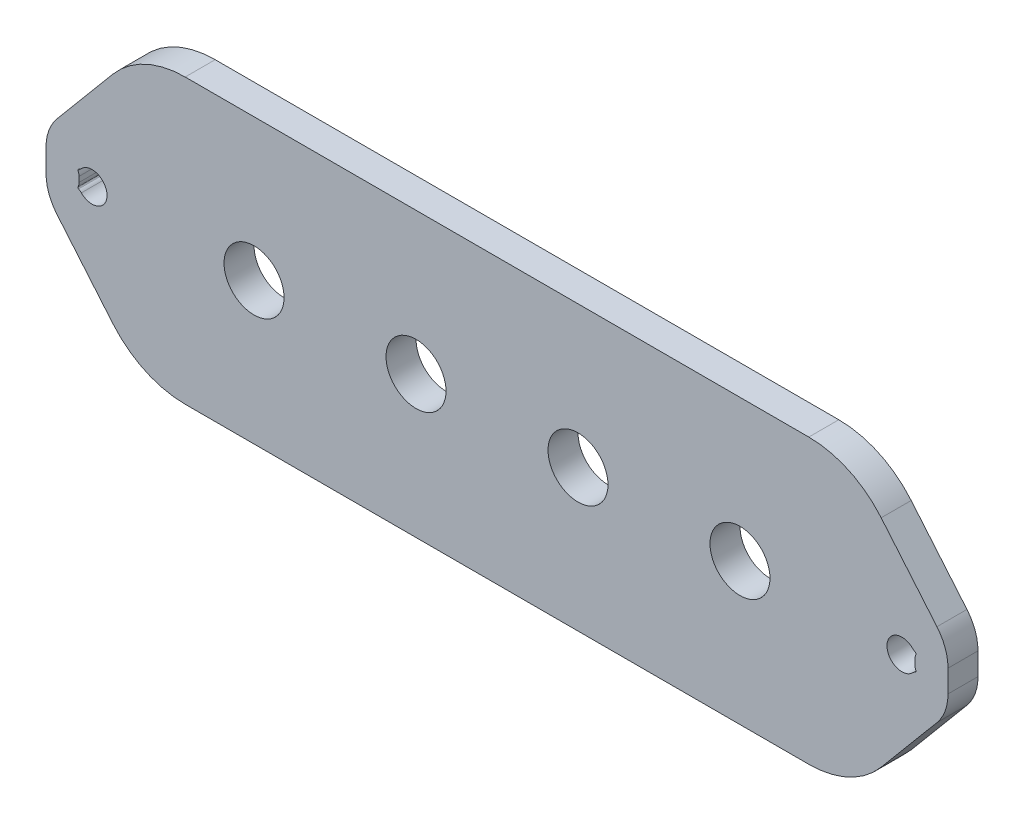
from build123d import *

# Parameters (mm, degrees)
SKETCH1_R           = 6.35
BOSS_EXTRUDE1_DEPTH = 3.175
FILLET1_R           = 2
FILLET2_R           = 10
FILLET3_R           = 20


with BuildPart() as part:
    # Sketch1 → Boss-Extrude1 (new, symmetric)
    with BuildSketch(Plane.XY):
        Polygon((75.336239509, 30), (-75.336239509, 30), (-95.474630657, 6), (-95.474630657, -6), (-75.336239509, -30), (75.336239509, -30), (95.474630657, -6), (95.474630657, 6), align=None)
        with BuildLine():
            Line((-88.474630657, -1.3375), (-88.474630657, 1.3375))
            ThreePointArc((-88.474630657, 1.3375), (-88.714791341, 1.656946712), (-88.341203698, 1.798917233))
            ThreePointArc((-88.341203698, 1.798917233), (-82.55, 0), (-88.341203698, -1.798917233))
            ThreePointArc((-88.341203698, -1.798917233), (-88.714791341, -1.656946712), (-88.474630657, -1.3375))
        make_face(mode=Mode.SUBTRACT)
        with Locations((-51.435, 0)):
            Circle(SKETCH1_R, mode=Mode.SUBTRACT)
        with Locations((-17.145, 0)):
            Circle(SKETCH1_R, mode=Mode.SUBTRACT)
        with Locations((17.145, 0)):
            Circle(SKETCH1_R, mode=Mode.SUBTRACT)
        with Locations((51.435, 0)):
            Circle(SKETCH1_R, mode=Mode.SUBTRACT)
        with BuildLine():
            ThreePointArc((88.341203698, 1.798917233), (88.714791341, 1.656946712), (88.474630657, 1.3375))
            Line((88.474630657, 1.3375), (88.474630657, -1.3375))
            ThreePointArc((88.474630657, -1.3375), (88.714791341, -1.656946712), (88.341203698, -1.798917233))
            ThreePointArc((88.341203698, -1.798917233), (82.55, 0), (88.341203698, 1.798917233))
        make_face(mode=Mode.SUBTRACT)
    extrude(amount=BOSS_EXTRUDE1_DEPTH, both=True)

    # Fillet1
    fillet1_edges = [part.edges().sort_by_distance(p)[0] for p in [
        (-88.341203698, 1.798917233, 0),
        (-88.474630657, 1.3375, 0),
        (-88.474630657, -1.3375, 0),
        (-88.341203698, -1.798917233, 0),
        (88.341203698, -1.798917233, 0),
        (88.474630657, -1.3375, 0),
        (88.474630657, 1.3375, 0),
        (88.341203698, 1.798917233, 0),
    ]]
    fillet(fillet1_edges, radius=FILLET1_R)

    # Fillet2
    fillet2_edges = [part.edges().sort_by_distance(p)[0] for p in [
        (95.474630657, 6, 0),
        (95.474630657, -6, 0),
        (-95.474630657, -6, 0),
        (-95.474630657, 6, 0),
    ]]
    fillet(fillet2_edges, radius=FILLET2_R)

    # Fillet3
    fillet3_edges = [part.edges().sort_by_distance(p)[0] for p in [
        (75.336239509, -30, 0),
        (-75.336239509, -30, 0),
        (-75.336239509, 30, 0),
        (75.336239509, 30, 0),
    ]]
    fillet(fillet3_edges, radius=FILLET3_R)


solid = part.part
